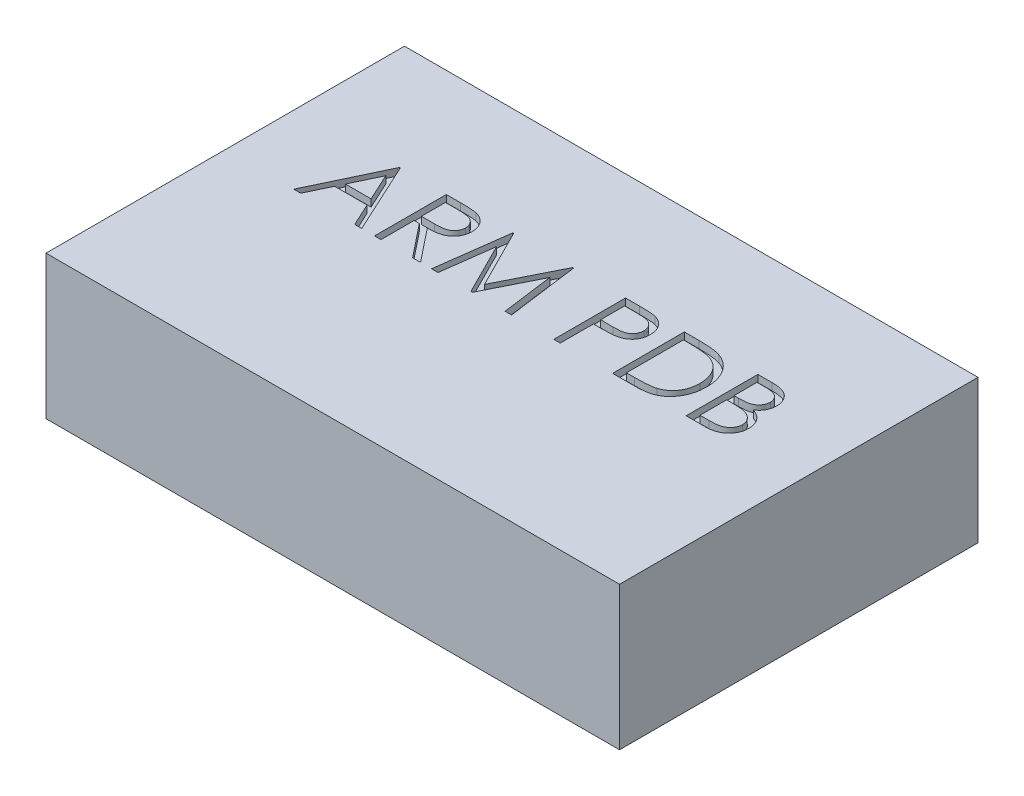
from build123d import *

# Parameters (mm, degrees)
SKETCH1_W           = 80
SKETCH1_H           = 50
BOSS_EXTRUDE1_DEPTH = 20
CUT_EXTRUDE1_DEPTH  = 1


with BuildPart() as part:
    # Sketch1 → Boss-Extrude1 (new body)
    with BuildSketch(Plane(origin=(0, 0, 0), x_dir=(1, 0, 0), z_dir=(0, 1, 0))):
        with Locations((40, 25)):
            Rectangle(SKETCH1_W, SKETCH1_H)
    extrude(amount=BOSS_EXTRUDE1_DEPTH)

    # Sketch2 → Cut-Extrude1 (cut)
    with BuildSketch(Plane(origin=(0, 20, 0), x_dir=(1, 0, 0), z_dir=(0, 1, 0))):
        Polygon((14.423076923, 35), (19.038461538, 25), (18.062900641, 25), (16.584535256, 28.205128205), (12.051282051, 28.205128205), (10.532852564, 25), (9.551282051, 25), (14.294871795, 35), align=None)
        Polygon((14.348958333, 33.048878205), (12.540064103, 29.230769231), (16.111778846, 29.230769231), align=None, mode=Mode.SUBTRACT)
        with BuildLine():
            Line((20.833333333, 35), (22.834535256, 35))
            add(Edge.make_bspline(
                [(22.834535256, 35), (22.968081338, 34.999555469), (23.224504608, 34.998701919), (23.591856809, 34.993942596), (23.925648514, 34.98030158), (24.225705198, 34.96856277), (24.492021355, 34.947157224), (24.725413614, 34.926698232), (24.924807036, 34.899916344), (25.045509468, 34.875043707), (25.100160256, 34.863782051)],
                knots=[0, 0, 0, 0, 1.410062039, 2.707475311, 3.878576406, 4.937260626, 5.877586885, 6.699081471, 7.410979367, 8, 8, 8, 8], degree=3))
            add(Edge.make_bspline(
                [(25.100160256, 34.863782051), (25.17332204, 34.845705579), (25.318084867, 34.809938254), (25.526513627, 34.734339395), (25.725125981, 34.646854753), (25.913096908, 34.544101266), (26.089484882, 34.425316181), (26.256108628, 34.292550117), (26.413724237, 34.146529529), (26.555957466, 33.983572839), (26.690069043, 33.812611383), (26.803179404, 33.627743506), (26.900683632, 33.434424856), (26.97831368, 33.230689377), (27.040822176, 33.018512886), (27.084897146, 32.795973467), (27.11132911, 32.564084967), (27.114020126, 32.405919513), (27.115384615, 32.325721154)],
                knots=[0, 0, 0, 0, 1.027469482, 2.033020251, 3.019912614, 3.986113645, 4.951240523, 5.91722682, 6.890402269, 7.87763091, 8.8651537, 9.85103654, 10.82876324, 11.815024772, 12.821070561, 13.842952187, 14.906261191, 16, 16, 16, 16], degree=3))
            add(Edge.make_bspline(
                [(27.115384615, 32.325721154), (27.111187478, 32.192477998), (27.102997776, 31.93248609), (27.026640337, 31.555169286), (26.901564566, 31.203199815), (26.729212312, 30.87702085), (26.509728095, 30.582990434), (26.245942978, 30.324731991), (25.937709802, 30.108617955), (25.650768899, 29.958752798), (25.397299758, 29.862773059), (25.18863315, 29.795240606), (24.961013214, 29.743063562), (24.716620829, 29.696320328), (24.454438956, 29.661029773), (24.175095987, 29.63518236), (23.878392696, 29.619027935), (23.674566784, 29.616622207), (23.569711538, 29.615384615)],
                knots=[0, 0, 0, 0, 1.260483769, 2.459530307, 3.627416485, 4.787058657, 5.939039949, 7.08810263, 8.267026773, 9.491475466, 10.141966685, 10.831826277, 11.566392101, 12.351337768, 13.187381173, 14.07005841, 15.007169909, 16, 16, 16, 16], degree=3))
            Line((23.569711538, 29.615384615), (27.243589744, 25))
            Line((27.243589744, 25), (26.133814103, 25))
            Line((26.133814103, 25), (22.459935897, 29.615384615))
            Line((22.459935897, 29.615384615), (21.730769231, 29.615384615))
            Line((21.730769231, 29.615384615), (21.730769231, 25))
            Line((21.730769231, 25), (20.833333333, 25))
            Line((20.833333333, 25), (20.833333333, 35))
        make_face()
        with BuildLine():
            Line((21.730769231, 33.974358974), (21.730769231, 30.641025641))
            Line((21.730769231, 30.641025641), (23.561698718, 30.627003205))
            add(Edge.make_bspline(
                [(23.561698718, 30.627003205), (23.647184543, 30.626965386), (23.812880421, 30.626892082), (24.052596606, 30.638302871), (24.275796925, 30.651283781), (24.481627646, 30.671139054), (24.670180718, 30.69672783), (24.841361899, 30.728736356), (24.995450618, 30.766027964), (25.175160728, 30.823746895), (25.375836532, 30.915192661), (25.593926417, 31.048236943), (25.779647382, 31.215577284), (25.93655556, 31.406930015), (26.06263965, 31.617319298), (26.151531234, 31.84422321), (26.207938212, 32.08191349), (26.214591199, 32.245279512), (26.217948718, 32.327724359)],
                knots=[0, 0, 0, 0, 1.146690395, 2.22261258, 3.21895312, 4.145990853, 4.996080663, 5.770904154, 6.481378293, 7.121626537, 8.300444488, 9.431385265, 10.535395872, 11.636531494, 12.74115979, 13.810798291, 14.895190096, 16, 16, 16, 16], degree=3))
            add(Edge.make_bspline(
                [(26.217948718, 32.327724359), (26.214514086, 32.408143141), (26.2077079, 32.567503823), (26.152139989, 32.800806424), (26.058170328, 33.02099771), (25.931535363, 33.227181953), (25.777252063, 33.414341198), (25.596344027, 33.574475921), (25.393757755, 33.706617249), (25.204411474, 33.791058336), (25.035170867, 33.842829345), (24.888228981, 33.879261242), (24.722196187, 33.908531153), (24.536266306, 33.931982755), (24.331233075, 33.952139739), (24.106059786, 33.96571625), (23.862240414, 33.973755861), (23.693249182, 33.974153258), (23.605769231, 33.974358974)],
                knots=[0, 0, 0, 0, 1.101028733, 2.181837193, 3.264309656, 4.369019818, 5.486613113, 6.575447106, 7.666700264, 8.788928104, 9.402425223, 10.0903467, 10.862060571, 11.710948788, 12.657782767, 13.684531032, 14.801375019, 16, 16, 16, 16], degree=3))
            Line((23.605769231, 33.974358974), (21.730769231, 33.974358974))
        make_face(mode=Mode.SUBTRACT)
        Polygon((28.782051282, 25), (30.102163462, 35), (30.23036859, 35), (34.358974359, 26.794871795), (38.475560897, 35), (38.603766026, 35), (39.935897436, 25), (39.038461538, 25), (38.076923077, 32.189503205), (34.469150641, 25), (34.264823718, 25), (30.641025641, 32.211538462), (29.685496795, 25), align=None)
        with BuildLine():
            Line((45.833333333, 35), (47.794471154, 35))
            add(Edge.make_bspline(
                [(47.794471154, 35), (47.929359457, 34.999851725), (48.187811437, 34.999567624), (48.558425881, 34.990954064), (48.895025115, 34.97944923), (49.196883346, 34.963500963), (49.46492934, 34.944653563), (49.697950196, 34.918219164), (49.8977775, 34.89061832), (50.017510213, 34.862557158), (50.072115385, 34.849759615)],
                knots=[0, 0, 0, 0, 1.415646017, 2.712440637, 3.8905458, 4.950247383, 5.884950622, 6.709939814, 7.411656543, 8, 8, 8, 8], degree=3))
            add(Edge.make_bspline(
                [(50.072115385, 34.849759615), (50.141239767, 34.830839759), (50.277859702, 34.793445868), (50.474719825, 34.718549515), (50.662016526, 34.629743329), (50.840392408, 34.528532072), (51.007655502, 34.410573318), (51.166301333, 34.280648696), (51.314929848, 34.1357585), (51.452705254, 33.977527814), (51.579233247, 33.808612929), (51.688175198, 33.626492272), (51.779395846, 33.434231405), (51.857633765, 33.231964059), (51.913943635, 33.017991706), (51.956363348, 32.793801099), (51.983287999, 32.55941627), (51.985866746, 32.39924522), (51.987179487, 32.317708333)],
                knots=[0, 0, 0, 0, 0.999701418, 1.975846123, 2.934577507, 3.890451536, 4.834027766, 5.787354733, 6.749476667, 7.726910423, 8.712836071, 9.690891519, 10.682875813, 11.679750201, 12.712814741, 13.765529915, 14.8625177, 16, 16, 16, 16], degree=3))
            add(Edge.make_bspline(
                [(51.987179487, 32.317708333), (51.985975417, 32.235486114), (51.983619571, 32.074612788), (51.95534447, 31.839261965), (51.917258208, 31.614352279), (51.858695202, 31.40038242), (51.781993278, 31.198623076), (51.692015985, 31.005990985), (51.583491612, 30.825763351), (51.458792099, 30.657285872), (51.320073258, 30.500400408), (51.167922006, 30.356243853), (51.002952599, 30.225660029), (50.825689318, 30.108356189), (50.634404036, 30.007052534), (50.431997883, 29.916317377), (50.21671155, 29.840114346), (50.067732939, 29.800028457), (49.991987179, 29.779647436)],
                knots=[0, 0, 0, 0, 1.121902311, 2.195077645, 3.232258892, 4.234102512, 5.217864754, 6.176164875, 7.132989551, 8.084763148, 9.034132444, 9.988522005, 10.94243251, 11.903244335, 12.886203696, 13.894208494, 14.929344452, 16, 16, 16, 16], degree=3))
            add(Edge.make_bspline(
                [(49.991987179, 29.779647436), (49.929337654, 29.766324633), (49.792037576, 29.737126935), (49.565915512, 29.704531344), (49.302642981, 29.676709628), (49.002579324, 29.655849235), (48.665993881, 29.637991039), (48.292704575, 29.623796485), (47.88197864, 29.615996903), (47.595489371, 29.615594638), (47.445913462, 29.615384615)],
                knots=[0, 0, 0, 0, 0.601384939, 1.31797006, 2.144135048, 3.087295005, 4.142315834, 5.309527816, 6.595305764, 8, 8, 8, 8], degree=3))
            Line((47.445913462, 29.615384615), (46.730769231, 29.615384615))
            Line((46.730769231, 29.615384615), (46.730769231, 25))
            Line((46.730769231, 25), (45.833333333, 25))
            Line((45.833333333, 25), (45.833333333, 35))
        make_face()
        with BuildLine():
            Line((46.730769231, 33.974358974), (46.730769231, 30.641025641))
            Line((46.730769231, 30.641025641), (48.481570513, 30.618990385))
            add(Edge.make_bspline(
                [(48.481570513, 30.618990385), (48.567056015, 30.618946203), (48.732084015, 30.618860911), (48.970473224, 30.630247264), (49.191642616, 30.643391643), (49.394912832, 30.662637139), (49.580375502, 30.689840731), (49.74833987, 30.71730284), (49.897503535, 30.757032447), (50.072072683, 30.81052693), (50.266596533, 30.901762975), (50.4782181, 31.034191232), (50.657562633, 31.202993256), (50.812757766, 31.39278706), (50.935917418, 31.603927429), (51.026077396, 31.829838677), (51.079052131, 32.068203962), (51.086155542, 32.23131293), (51.08974359, 32.313701923)],
                knots=[0, 0, 0, 0, 1.160613943, 2.240541288, 3.23993089, 4.169200891, 5.011653406, 5.7853311, 6.478053781, 7.106038997, 8.262395093, 9.384106736, 10.481365981, 11.59014053, 12.70357646, 13.786202915, 14.881775077, 16, 16, 16, 16], degree=3))
            add(Edge.make_bspline(
                [(51.08974359, 32.313701923), (51.086136028, 32.394097676), (51.078964643, 32.553914482), (51.025662177, 32.788139512), (50.936092708, 33.011670096), (50.81193101, 33.220164626), (50.661242067, 33.409275494), (50.486101087, 33.573553), (50.28692034, 33.705615008), (50.10163968, 33.790852956), (49.937064863, 33.8428966), (49.794116406, 33.87931043), (49.632714479, 33.90838359), (49.452806537, 33.931925027), (49.255787012, 33.952077773), (49.039963255, 33.965751994), (48.806152846, 33.973756154), (48.643836929, 33.974153169), (48.559695513, 33.974358974)],
                knots=[0, 0, 0, 0, 1.120700087, 2.227813068, 3.331159281, 4.466773991, 5.599788987, 6.693661531, 7.80175334, 8.91857717, 9.525282508, 10.207424825, 10.974604443, 11.810962634, 12.737642355, 13.736264703, 14.826523623, 16, 16, 16, 16], degree=3))
            Line((48.559695513, 33.974358974), (46.730769231, 33.974358974))
        make_face(mode=Mode.SUBTRACT)
        with BuildLine():
            Line((54.038461538, 25), (54.038461538, 35))
            Line((54.038461538, 35), (56.057692308, 35))
            add(Edge.make_bspline(
                [(56.057692308, 35), (56.233317988, 34.998735514), (56.572625889, 34.996292535), (57.062947168, 34.980802846), (57.51661506, 34.953401515), (57.932137515, 34.913488583), (58.310655263, 34.864479915), (58.651108429, 34.803050189), (58.955257409, 34.730512559), (59.142312954, 34.668668415), (59.230769231, 34.639423077)],
                knots=[0, 0, 0, 0, 1.314313732, 2.53924729, 3.670748893, 4.714932338, 5.66265055, 6.526160246, 7.303039223, 8, 8, 8, 8], degree=3))
            add(Edge.make_bspline(
                [(59.230769231, 34.639423077), (59.346468486, 34.595335347), (59.575243321, 34.508159649), (59.900977957, 34.343713074), (60.207621851, 34.157389926), (60.496819408, 33.948944604), (60.761964626, 33.712475037), (61.01341576, 33.458026221), (61.240886399, 33.176345249), (61.449195816, 32.873273855), (61.637011986, 32.552382277), (61.800266723, 32.214281966), (61.935849561, 31.860689943), (62.048401637, 31.49258952), (62.137105801, 31.109171298), (62.197625606, 30.709988824), (62.23754272, 30.296619711), (62.241554295, 30.016121243), (62.243589744, 29.873798077)],
                knots=[0, 0, 0, 0, 0.984719456, 1.947108742, 2.898477687, 3.838006223, 4.779231079, 5.722358779, 6.681677486, 7.655904652, 8.64651281, 9.637519902, 10.640069247, 11.656948941, 12.698408672, 13.768548281, 14.867775369, 16, 16, 16, 16], degree=3))
            add(Edge.make_bspline(
                [(62.243589744, 29.873798077), (62.241792694, 29.750194538), (62.238251419, 29.506620856), (62.206453374, 29.147646868), (62.160235316, 28.799322379), (62.088680465, 28.463306093), (62.001816141, 28.136654042), (61.890489995, 27.822847629), (61.762960006, 27.519008174), (61.614246067, 27.229243957), (61.450984967, 26.954720036), (61.275779986, 26.695932813), (61.088818, 26.456575036), (60.888316191, 26.235921859), (60.676865573, 26.034305921), (60.453081771, 25.85004302), (60.21638734, 25.686738578), (59.967842418, 25.537975411), (59.700196335, 25.408202967), (59.408379574, 25.298402939), (59.091147637, 25.207412609), (58.749279189, 25.131495764), (58.382183538, 25.071274899), (57.989500779, 25.030913778), (57.571834237, 25.003619685), (57.285036336, 25.001229989), (57.137419872, 25)],
                knots=[0, 0, 0, 0, 1.105936401, 2.179363191, 3.223086493, 4.248585256, 5.251745608, 6.245858792, 7.225916811, 8.198733463, 9.158002045, 10.082870192, 10.993790845, 11.873723703, 12.748670949, 13.606408763, 14.465103618, 15.319838547, 16.196477973, 17.123216899, 18.106603292, 19.147568657, 20.255746949, 21.433717677, 22.679120308, 24, 24, 24, 24], degree=3))
            Line((57.137419872, 25), (54.038461538, 25))
        make_face()
        with BuildLine():
            Line((54.935897436, 26.025641026), (56.083733974, 26.025641026))
            add(Edge.make_bspline(
                [(56.083733974, 26.025641026), (56.248672176, 26.026349872), (56.565908743, 26.027713244), (57.02207445, 26.039676682), (57.438872726, 26.059225075), (57.816362752, 26.08658244), (58.154331393, 26.122778483), (58.453484964, 26.163135348), (58.712842845, 26.213413779), (58.869784094, 26.258987949), (58.942307692, 26.280048077)],
                knots=[0, 0, 0, 0, 1.375205317, 2.645023457, 3.804390687, 4.853969522, 5.800190428, 6.637939096, 7.370582563, 8, 8, 8, 8], degree=3))
            add(Edge.make_bspline(
                [(58.942307692, 26.280048077), (59.033588727, 26.312195386), (59.21397055, 26.375722167), (59.473630794, 26.491601199), (59.715793664, 26.628864255), (59.944679451, 26.781442181), (60.157041323, 26.954716472), (60.355395941, 27.144919298), (60.539343945, 27.353018655), (60.706984825, 27.578756259), (60.857008551, 27.820727104), (60.986926349, 28.076552343), (61.100787868, 28.343428944), (61.190155276, 28.625455111), (61.260199802, 28.920109564), (61.309813196, 29.22741303), (61.340712409, 29.547308121), (61.344316546, 29.764885619), (61.346153846, 29.875801282)],
                knots=[0, 0, 0, 0, 0.998632004, 1.973411704, 2.929992603, 3.868527914, 4.809262121, 5.754881198, 6.702106254, 7.672490631, 8.653608572, 9.636854334, 10.631411391, 11.644891563, 12.686317036, 13.754757253, 14.855430412, 16, 16, 16, 16], degree=3))
            add(Edge.make_bspline(
                [(61.346153846, 29.875801282), (61.344687311, 29.992754083), (61.341806289, 30.222508895), (61.305593974, 30.559625168), (61.252675244, 30.883855598), (61.176150426, 31.19522187), (61.07863363, 31.494331448), (60.956934653, 31.779530048), (60.81788717, 32.053829674), (60.652449064, 32.31089929), (60.471261655, 32.554022459), (60.270182, 32.776750789), (60.052404747, 32.979591647), (59.820305177, 33.165703969), (59.567342036, 33.327600186), (59.299474348, 33.472419275), (59.01277243, 33.595321821), (58.813307585, 33.660690001), (58.711939103, 33.693910256)],
                knots=[0, 0, 0, 0, 1.122418816, 2.205001699, 3.251619955, 4.274784885, 5.280384055, 6.268708349, 7.249350384, 8.229342522, 9.199999885, 10.157847722, 11.105861043, 12.055065948, 13.010012805, 13.98527497, 14.976112212, 16, 16, 16, 16], degree=3))
            add(Edge.make_bspline(
                [(58.711939103, 33.693910256), (58.628078684, 33.71710005), (58.449768426, 33.766407915), (58.158798529, 33.820194693), (57.831326674, 33.867636119), (57.465898956, 33.907801946), (57.06293193, 33.936622864), (56.622115679, 33.958255191), (56.143259666, 33.97284557), (55.811309569, 33.973841876), (55.639022436, 33.974358974)],
                knots=[0, 0, 0, 0, 0.674548936, 1.434276114, 2.292660221, 3.240891867, 4.284742987, 5.42552168, 6.663806718, 8, 8, 8, 8], degree=3))
            Line((55.639022436, 33.974358974), (54.935897436, 33.974358974))
            Line((54.935897436, 33.974358974), (54.935897436, 26.025641026))
        make_face(mode=Mode.SUBTRACT)
        with BuildLine():
            Line((64.294871795, 35), (66.24599359, 35))
            add(Edge.make_bspline(
                [(66.24599359, 35), (66.341503527, 34.999497856), (66.526625557, 34.998524576), (66.795823962, 34.983429916), (67.047963421, 34.962848002), (67.283117056, 34.930190594), (67.501176206, 34.890785516), (67.702798027, 34.843066042), (67.887341376, 34.785847146), (68.10766348, 34.694857771), (68.358865368, 34.559648718), (68.630860776, 34.359852818), (68.863444317, 34.115474352), (69.063976652, 33.839809622), (69.223408422, 33.53656456), (69.338749272, 33.212966878), (69.411771773, 32.873190472), (69.419281585, 32.63992425), (69.423076923, 32.522035256)],
                knots=[0, 0, 0, 0, 1.001505555, 1.941167018, 2.826882275, 3.653841531, 4.429895133, 5.150066043, 5.825578002, 6.45369114, 7.647487171, 8.808567382, 9.977351308, 11.170798116, 12.373658725, 13.556498008, 14.765093433, 16, 16, 16, 16], degree=3))
            add(Edge.make_bspline(
                [(69.423076923, 32.522035256), (69.419953442, 32.411599383), (69.413815507, 32.194582477), (69.355121908, 31.877170736), (69.263234284, 31.575024397), (69.135505001, 31.289246153), (68.969499298, 31.026292972), (68.772761244, 30.784043641), (68.535398951, 30.572754907), (68.357561123, 30.454632328), (68.267227564, 30.39463141)],
                knots=[0, 0, 0, 0, 1.044552857, 2.05264487, 3.044412934, 4.028983338, 5.005914585, 5.980388656, 6.974128949, 8, 8, 8, 8], degree=3))
            add(Edge.make_bspline(
                [(68.267227564, 30.39463141), (68.380828786, 30.351017128), (68.598176064, 30.267572201), (68.897278957, 30.120042304), (69.154978514, 29.959579131), (69.373256074, 29.784345273), (69.559935088, 29.595462957), (69.722943492, 29.390162631), (69.862033133, 29.165766179), (69.981212914, 28.924613221), (70.07420936, 28.669166169), (70.143854801, 28.401821094), (70.183761799, 28.123536651), (70.189440774, 27.934149853), (70.192307692, 27.838541667)],
                knots=[0, 0, 0, 0, 1.27268992, 2.434971085, 3.483601985, 4.442670788, 5.356604649, 6.2567628, 7.179492994, 8.113709626, 9.066344395, 10.018646069, 10.999752585, 12, 12, 12, 12], degree=3))
            add(Edge.make_bspline(
                [(70.192307692, 27.838541667), (70.189516704, 27.740922032), (70.184025355, 27.548852666), (70.14351115, 27.266695139), (70.074913702, 26.997052434), (69.980424712, 26.738180484), (69.857103813, 26.490580099), (69.707023915, 26.253970774), (69.52807659, 26.030729829), (69.327896965, 25.81837662), (69.101433692, 25.627440085), (68.857102964, 25.457395209), (68.591827764, 25.317549317), (68.309964924, 25.20007497), (68.008352592, 25.110340117), (67.688345143, 25.047561334), (67.350218566, 25.005261229), (67.118190706, 25.0017835), (66.999198718, 25)],
                knots=[0, 0, 0, 0, 0.978564426, 1.925352924, 2.850884081, 3.763762016, 4.682927383, 5.618979971, 6.567305752, 7.547517671, 8.540179244, 9.531824382, 10.526200242, 11.540722885, 12.589160233, 13.674978461, 14.80764778, 16, 16, 16, 16], degree=3))
            Line((66.999198718, 25), (64.294871795, 25))
            Line((64.294871795, 25), (64.294871795, 35))
        make_face()
        with BuildLine():
            Line((65.192307692, 33.974358974), (65.192307692, 30.769230769))
            Line((65.192307692, 30.769230769), (65.795272436, 30.769230769))
            add(Edge.make_bspline(
                [(65.795272436, 30.769230769), (65.883411851, 30.770373406), (66.053715163, 30.772581214), (66.300343439, 30.778905549), (66.529272063, 30.796614244), (66.740105871, 30.81431785), (66.932512854, 30.843102386), (67.106066744, 30.877365595), (67.263491307, 30.913602466), (67.445032866, 30.975229572), (67.650955575, 31.066308644), (67.87047873, 31.207656747), (68.064005786, 31.376012042), (68.227426323, 31.570271932), (68.361173381, 31.784175321), (68.45406971, 32.014309265), (68.517061951, 32.254938213), (68.52275204, 32.420133221), (68.525641026, 32.50400641)],
                knots=[0, 0, 0, 0, 1.156816544, 2.235205308, 3.236616184, 4.169592532, 5.011045266, 5.787822928, 6.49130361, 7.128639758, 8.301311294, 9.436451833, 10.541879658, 11.654887649, 12.756523258, 13.837046038, 14.901820046, 16, 16, 16, 16], degree=3))
            add(Edge.make_bspline(
                [(68.525641026, 32.50400641), (68.524137654, 32.559508615), (68.521188625, 32.668382249), (68.497036332, 32.82709469), (68.45598612, 32.976362554), (68.403259567, 33.118231441), (68.3295776, 33.248265298), (68.242824847, 33.370960143), (68.138008589, 33.482137625), (68.018701982, 33.586050477), (67.881534488, 33.678177699), (67.72658794, 33.758865594), (67.551766005, 33.823839242), (67.360014991, 33.880742534), (67.148383313, 33.920709088), (66.91931316, 33.954004482), (66.670928249, 33.970955173), (66.499085098, 33.973199067), (66.41025641, 33.974358974)],
                knots=[0, 0, 0, 0, 0.91205012, 1.789085906, 2.630437955, 3.453916878, 4.269457761, 5.079663411, 5.91843418, 6.774407191, 7.675494373, 8.627863946, 9.638891023, 10.736472738, 11.911756761, 13.175263542, 14.539845004, 16, 16, 16, 16], degree=3))
            Line((66.41025641, 33.974358974), (65.192307692, 33.974358974))
        make_face(mode=Mode.SUBTRACT)
        with BuildLine():
            Line((65.192307692, 29.743589744), (65.192307692, 26.025641026))
            Line((65.192307692, 26.025641026), (66.470352564, 26.025641026))
            add(Edge.make_bspline(
                [(66.470352564, 26.025641026), (66.56183521, 26.026737447), (66.738155948, 26.028850654), (66.992730892, 26.035749381), (67.228682617, 26.051441598), (67.444934433, 26.076144025), (67.643821441, 26.102939594), (67.822957735, 26.138971825), (67.983795431, 26.18025457), (68.170293453, 26.24406649), (68.380303476, 26.343199265), (68.606620209, 26.492668483), (68.807837975, 26.670735076), (68.978710144, 26.876823403), (69.118747254, 27.100912908), (69.220619983, 27.338471051), (69.283451002, 27.585572558), (69.2910572, 27.754048879), (69.294871795, 27.838541667)],
                knots=[0, 0, 0, 0, 1.160039823, 2.235823828, 3.228722157, 4.157150951, 4.99529583, 5.772374946, 6.472645482, 7.099169577, 8.269452708, 9.405989375, 10.527446681, 11.663510218, 12.788923519, 13.866172445, 14.929861265, 16, 16, 16, 16], degree=3))
            add(Edge.make_bspline(
                [(69.294871795, 27.838541667), (69.294082925, 27.891379782), (69.292517911, 27.99620373), (69.268916154, 28.150248928), (69.234590812, 28.299465709), (69.190215286, 28.444259253), (69.125588237, 28.582011757), (69.050140966, 28.715447641), (68.961679818, 28.844743297), (68.823839344, 29.008206878), (68.62334796, 29.196541201), (68.338471459, 29.380934064), (68.014550608, 29.529642085), (67.779614914, 29.592783446), (67.658253205, 29.625400641)],
                knots=[0, 0, 0, 0, 0.723448775, 1.435228256, 2.130040452, 2.821711965, 3.505591119, 4.210454504, 4.921174351, 5.648778258, 7.137944449, 8.670945889, 10.280296675, 12, 12, 12, 12], degree=3))
            add(Edge.make_bspline(
                [(67.658253205, 29.625400641), (67.609598646, 29.635272309), (67.504105525, 29.656676123), (67.332083866, 29.679269561), (67.135695669, 29.699398304), (66.914487449, 29.714287326), (66.668179331, 29.72967745), (66.396245278, 29.735662653), (66.099795807, 29.742803396), (65.894103315, 29.743320923), (65.787259615, 29.743589744)],
                knots=[0, 0, 0, 0, 0.634451884, 1.375622551, 2.216452059, 3.157844607, 4.20941857, 5.370758133, 6.634282058, 8, 8, 8, 8], degree=3))
            Line((65.787259615, 29.743589744), (65.192307692, 29.743589744))
        make_face(mode=Mode.SUBTRACT)
    extrude(amount=-CUT_EXTRUDE1_DEPTH, mode=Mode.SUBTRACT)


solid = part.part
